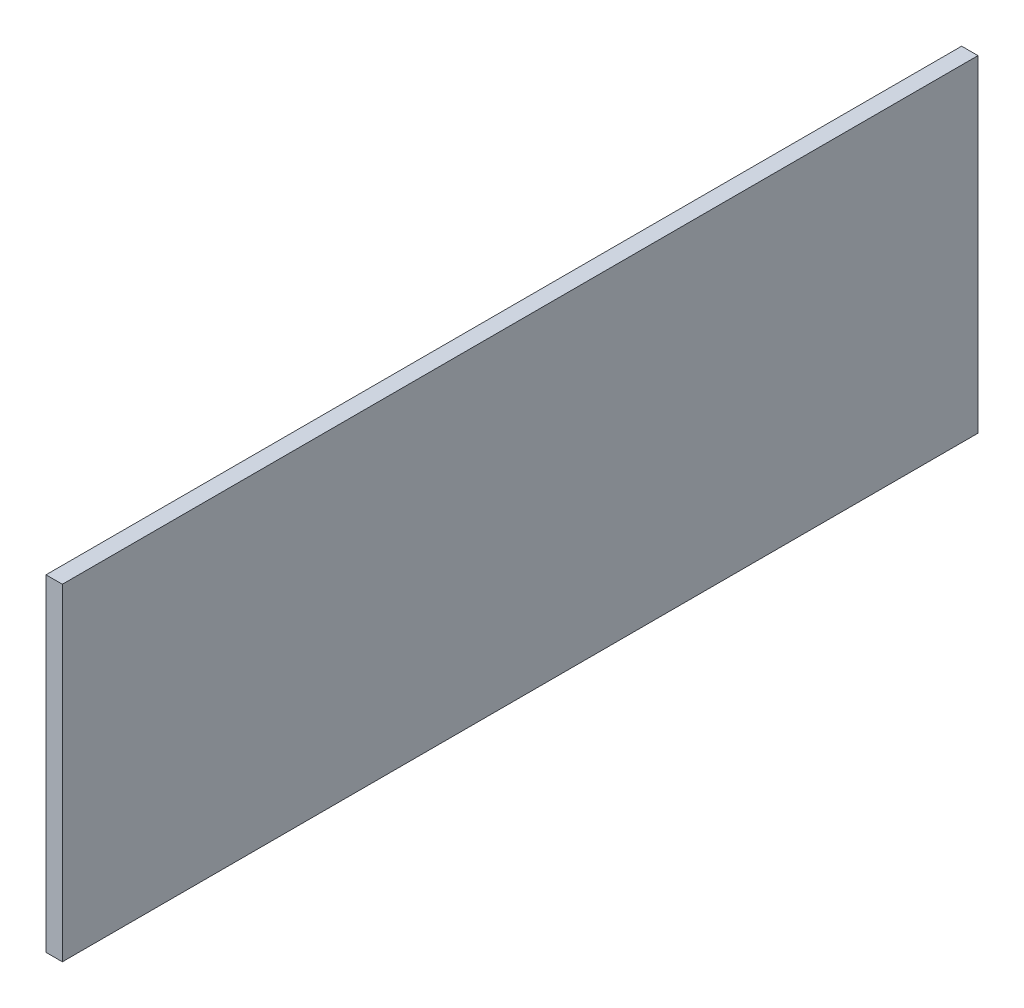
from build123d import *

# Parameters (mm, degrees)
SKETCH1_W           = 88.9
SKETCH1_H           = 31.75
BOSS_EXTRUDE1_DEPTH = 0.79375


with BuildPart() as part:
    # Sketch1 → Boss-Extrude1 (new body, symmetric)
    with BuildSketch(Plane(origin=(0, 0, 0), x_dir=(0, 0, -1), z_dir=(1, 0, 0))):
        Rectangle(SKETCH1_W, SKETCH1_H)
    extrude(amount=BOSS_EXTRUDE1_DEPTH, both=True)


solid = part.part
